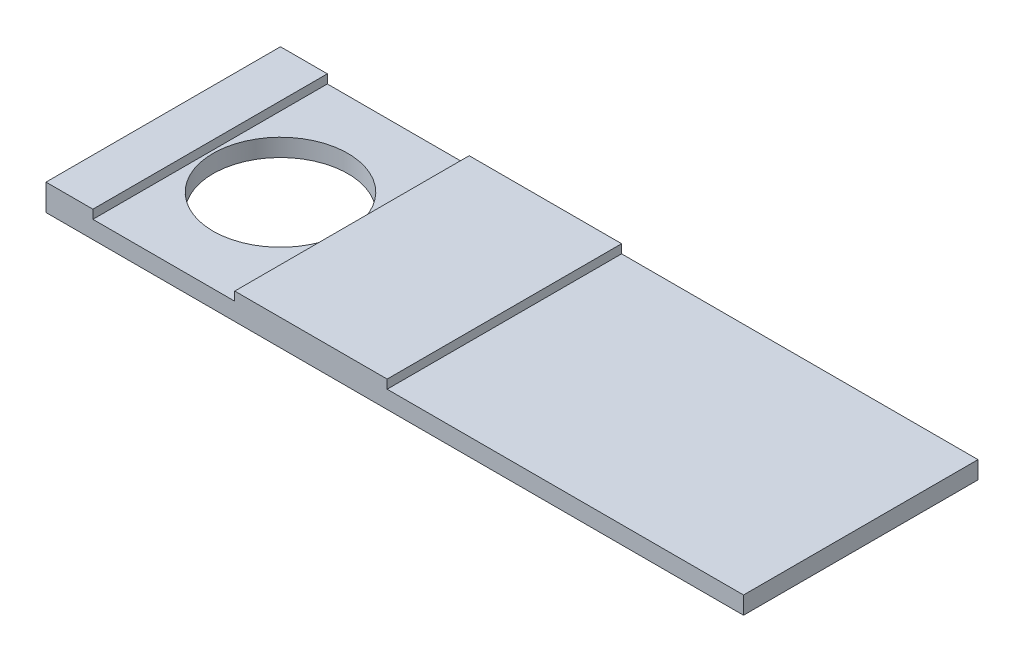
from build123d import *

# Parameters (mm, degrees)
SKETCH1_W           = 119
SKETCH1_H           = 40
SKETCH1_R           = 11.5
BOSS_EXTRUDE1_DEPTH = 3
SKETCH2_W           = 26
SKETCH2_H           = 40
SKETCH2_W_2         = 8
BOSS_EXTRUDE2_DEPTH = 1.5


with BuildPart() as part:
    # Sketch1 → Boss-Extrude1 (new body)
    with BuildSketch(Plane(origin=(0, 0, 0), x_dir=(1, 0, 0), z_dir=(0, 1, 0))):
        Rectangle(SKETCH1_W, SKETCH1_H)
        with Locations((-39.5, 0)):
            Circle(SKETCH1_R, mode=Mode.SUBTRACT)
    extrude(amount=BOSS_EXTRUDE1_DEPTH)

    # Sketch2 → Boss-Extrude2 (add)
    with BuildSketch(Plane(origin=(0, 3, 0), x_dir=(1, 0, 0), z_dir=(0, 1, 0))):
        with Locations((-14.3, 0)):
            Rectangle(SKETCH2_W, SKETCH2_H)
        with Locations((-55.5, 0)):
            Rectangle(SKETCH2_W_2, SKETCH2_H)
    extrude(amount=BOSS_EXTRUDE2_DEPTH)


solid = part.part
